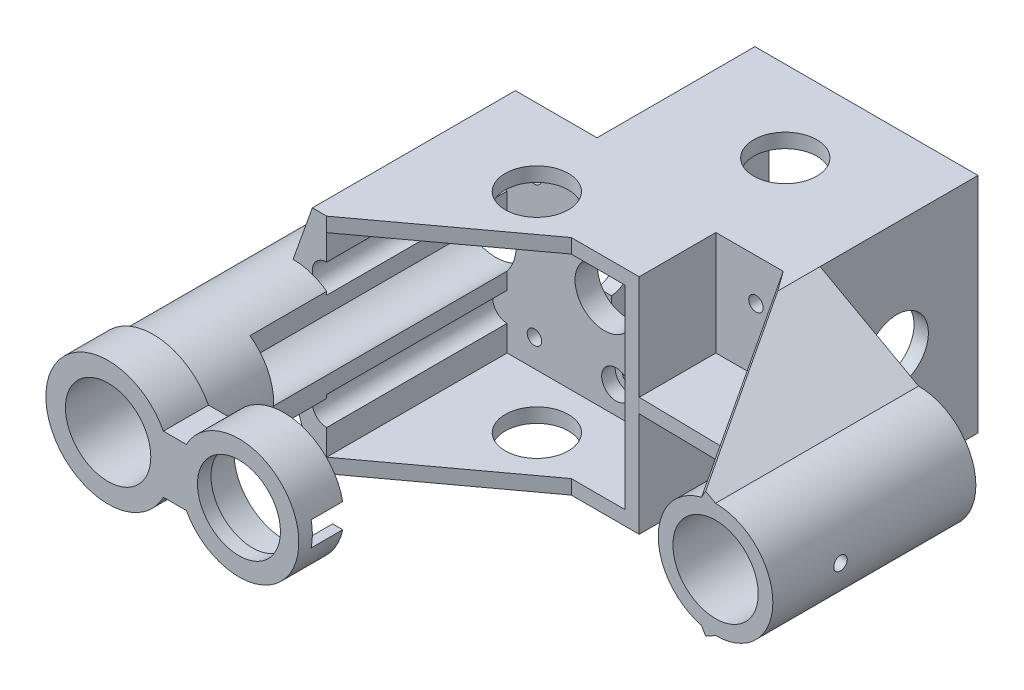
from build123d import *

# Parameters (mm, degrees)
SKETCH5_R       = 9.46
SKETCH5_R_2     = 1.6
EXTRUDE1_DEPTH  = 5
SKETCH6_R       = 9.46
EXTRUDE2_DEPTH  = 40
SKETCH7_W       = 49.45
SKETCH7_H       = 49.45
SKETCH7_W_2     = 43.1
SKETCH7_H_2     = 43.1
EXTRUDE3_DEPTH  = 35
EXTRUDE5_REACH  = 20.597
EXTRUDE6_REACH  = 20.597
SKETCH16_R      = 7
EXTRUDE9_DEPTH  = 49.45
EXTRUDE10_DEPTH = 17
SKETCH18_R      = 12.7
SKETCH18_R_2    = 9.46
EXTRUDE11_DEPTH = 14
SKETCH19_R      = 11.1
SKETCH19_R_2    = 9.46
EXTRUDE12_DEPTH = 7
SKETCH20_R      = 9.46
SKETCH20_R_2    = 9.2
EXTRUDE13_DEPTH = 3
EXTRUDE14_DEPTH = 15
SKETCH22_R      = 3.2
EXTRUDE15_DEPTH = 3
SKETCH23_R      = 3.2
EXTRUDE16_DEPTH = 3
SKETCH24_R      = 7
EXTRUDE17_DEPTH = 49.45
SKETCH25_R      = 6.5
EXTRUDE18_DEPTH = 5
EXTRUDE19_START = -25.300694
SKETCH26_R      = 1.5
EXTRUDE19_DEPTH = 119.050001


with BuildPart() as part:
    # Sketch5 → Extrude1 (new body)
    with BuildSketch(Plane.XY):
        with BuildLine():
            Line((-21.825, -24.725), (0, -12.7))
            ThreePointArc((0, -12.7), (12.7, 0), (0, 12.7))
            Line((0, 12.7), (-21.825, 24.725))
            Line((-21.825, 24.725), (-89.375, 24.725))
            Line((-89.375, 24.725), (-93.65, 12.7))
            ThreePointArc((-93.65, 12.7), (-106.35, 0), (-93.65, -12.7))
            Line((-93.65, -12.7), (-89.375, -24.725))
            Line((-89.375, -24.725), (-21.825, -24.725))
        make_face()
        Circle(SKETCH5_R, mode=Mode.SUBTRACT)
        with Locations((-93.65, 0)):
            Circle(SKETCH5_R, mode=Mode.SUBTRACT)
        with Locations((-31.05, 15.5)):
            Circle(SKETCH5_R_2, mode=Mode.SUBTRACT)
        with Locations((-31.05, -15.5)):
            Circle(SKETCH5_R_2, mode=Mode.SUBTRACT)
        with Locations((-49.15, -15.5)):
            Circle(SKETCH5_R_2, mode=Mode.SUBTRACT)
        with Locations((-49.15, 15.5)):
            Circle(SKETCH5_R_2, mode=Mode.SUBTRACT)
        with Locations((-62.05, 15.5)):
            Circle(SKETCH5_R_2, mode=Mode.SUBTRACT)
        with Locations((-80.15, 15.5)):
            Circle(SKETCH5_R_2, mode=Mode.SUBTRACT)
        with Locations((-80.15, -15.5)):
            Circle(SKETCH5_R_2, mode=Mode.SUBTRACT)
        with Locations((-62.05, -15.5)):
            Circle(SKETCH5_R_2, mode=Mode.SUBTRACT)
    extrude(amount=EXTRUDE1_DEPTH)

    # Sketch6 → Extrude2 (add)
    with BuildSketch(Plane.XY.offset(5)):
        with BuildLine():
            Line((-39.925, 24.725), (-89.375, 24.725))
            Line((-89.375, 24.725), (-93.65, 12.7))
            ThreePointArc((-93.65, 12.7), (-106.35, 0), (-93.65, -12.7))
            Line((-93.65, -12.7), (-89.375, -24.725))
            Line((-89.375, -24.725), (-39.925, -24.725))
            Line((-39.925, -24.725), (-39.925, -1.585093616))
            Line((-39.925, -1.585093616), (-12.600693561, -1.585093616))
            ThreePointArc((-12.600693561, -1.585093616), (-9.51301391, -8.413831847), (-3.112651943, -12.312651943))
            Line((-3.112651943, -12.312651943), (-25, -24.725))
            Line((-25, -24.725), (-21.825, -24.725))
            Line((-21.825, -24.725), (0, -12.7))
            ThreePointArc((0, -12.7), (12.7, 0), (0, 12.7))
            Line((0, 12.7), (-21.825, 24.725))
            Line((-21.825, 24.725), (-25, 24.725))
            Line((-25, 24.725), (-3.112651943, 12.312651943))
            ThreePointArc((-3.112651943, 12.312651943), (-9.513885465, 8.41284633), (-12.601021697, 1.58248292))
            Line((-12.601021697, 1.58248292), (-39.925, 1.58248292))
            Line((-39.925, 1.58248292), (-39.925, 24.725))
        make_face()
        Circle(SKETCH6_R, mode=Mode.SUBTRACT)
        with BuildLine():
            Line((-86.2, -21.55), (-43.1, -21.55))
            Line((-43.1, -21.55), (-43.1, 21.55))
            Line((-43.1, 21.55), (-86.2, 21.55))
            Line((-86.2, 21.55), (-86.2, 15.891608363))
            ThreePointArc((-86.2, 15.891608363), (-89.375, 12.716608363), (-86.2, 9.541608363))
            Line((-86.2, 9.541608363), (-86.2, 5.830017153))
            ThreePointArc((-86.2, 5.830017153), (-103.11, 0), (-86.2, -5.830017153))
            Line((-86.2, -5.830017153), (-86.2, -9.508391637))
            ThreePointArc((-86.2, -9.508391637), (-89.375, -12.683391637), (-86.2, -15.858391637))
            Line((-86.2, -15.858391637), (-86.2, -21.55))
        make_face(mode=Mode.SUBTRACT)
    extrude(amount=EXTRUDE2_DEPTH)

    # Sketch7 → Extrude3 (add)
    with BuildSketch(Plane(origin=(0, 0, 0), x_dir=(-1, 0, 0), z_dir=(0, 0, -1))):
        with Locations((46.55, 0)):
            Rectangle(SKETCH7_W, SKETCH7_H)
        with Locations((46.55, 0)):
            Rectangle(SKETCH7_W_2, SKETCH7_H_2, mode=Mode.SUBTRACT)
    extrude(amount=EXTRUDE3_DEPTH)

    # Extrude5: up to this face of the body (flat: up to its plane)
    extrude5_end = Plane(part.part.faces().sort_by_distance((-10.9125, 18.7125, 22.5))[0])
    # Sketch12 → Extrude5 (cut, up to the picked face)
    with BuildSketch(Plane(origin=(4.5259255, 7.980803168, 0), x_dir=(0, 0, 1), z_dir=(-0.493298857, -0.869859895, 0)), mode=Mode.PRIVATE) as extrude5_sk1:
        Polygon((45, 8.781388226), (5, 33.943311626), (45, 33.943311626), align=None)
    extrude5_tool1 = split(extrude(extrude5_sk1.sketch, amount=-EXTRUDE5_REACH, mode=Mode.PRIVATE), bisect_by=extrude5_end, keep=Keep.BOTH, mode=Mode.PRIVATE)
    add(extrude5_tool1.solids().sort_by_distance((-17.704217, 20.587551, 31.666667))[0], mode=Mode.SUBTRACT)

    # Extrude6: up to this face of the body (flat: up to its plane)
    extrude6_end = Plane(part.part.faces().sort_by_distance((-10.9125, -18.7125, 22.5))[0])
    # Sketch13 → Extrude6 (cut, up to the picked face)
    with BuildSketch(Plane(origin=(4.5259255, -7.980803168, 0), x_dir=(0, 0, 1), z_dir=(-0.493298857, 0.869859895, 0)), mode=Mode.PRIVATE) as extrude6_sk1:
        Polygon((45, -8.781388226), (5, -33.943311626), (45, -33.943311626), align=None)
    extrude6_tool1 = split(extrude(extrude6_sk1.sketch, amount=-EXTRUDE6_REACH, mode=Mode.PRIVATE), bisect_by=extrude6_end, keep=Keep.BOTH, mode=Mode.PRIVATE)
    add(extrude6_tool1.solids().sort_by_distance((-17.704217, -20.587551, 31.666667))[0], mode=Mode.SUBTRACT)

    # Sketch16 → Extrude9 (cut)
    with BuildSketch(Plane.XZ.offset(24.725)):
        with Locations((-46.55, -17)):
            Circle(SKETCH16_R)
        with Locations((-67.618096531, 17)):
            Circle(SKETCH16_R)
        Polygon((-39.925, 22), (-16.781973348, 22.403360483), (-12.600693561, 29.053940018), (-12.600693561, 45), (-86.2, 45), (-54.981583076, 22), align=None)
    extrude(amount=-EXTRUDE9_DEPTH, mode=Mode.SUBTRACT)

    # Sketch17 → Extrude10 (add)
    with BuildSketch(Plane.XY.offset(45)):
        with BuildLine():
            Line((-86.2, 10.285305051), (-86.2, 5.830017153))
            ThreePointArc((-86.2, 5.830017153), (-103.11, 0), (-86.2, -5.830017153))
            Line((-86.2, -5.830017153), (-86.2, -10.285305051))
            ThreePointArc((-86.2, -10.285305051), (-89.146529591, -11.874710703), (-92.40601106, -12.638927625))
            ThreePointArc((-92.40601106, -12.638927625), (-106.334722718, -0.62274359), (-93.65, 12.7))
            ThreePointArc((-93.65, 12.7), (-89.734222565, 12.081253539), (-86.2, 10.285305051))
        make_face()
    extrude(amount=EXTRUDE10_DEPTH)

    # Sketch18 → Extrude11 (add)
    with BuildSketch(Plane.XY.offset(62)):
        with Locations((-93.65, 0)):
            Circle(SKETCH18_R)
        with Locations((-93.65, 0)):
            Circle(SKETCH18_R_2, mode=Mode.SUBTRACT)
    extrude(amount=EXTRUDE11_DEPTH)

    # Sketch19 → Extrude12 (add)
    with BuildSketch(Plane.XY.offset(76)):
        with BuildLine():
            Line((-81.398348387, -6.344577353), (-76.315821236, -6.344577353))
            ThreePointArc((-76.315821236, -6.344577353), (-51.370502761, 0), (-76.315821236, 6.344577353))
            Line((-76.315821236, 6.344577353), (-81.398348387, 6.344577353))
            ThreePointArc((-81.398348387, 6.344577353), (-107.446978982, 0), (-81.398348387, -6.344577353))
        make_face()
        with Locations((-64.65, 0)):
            Circle(SKETCH19_R, mode=Mode.SUBTRACT)
        with Locations((-93.65, 0)):
            Circle(SKETCH19_R_2, mode=Mode.SUBTRACT)
    extrude(amount=EXTRUDE12_DEPTH)

    # Sketch20 → Extrude13 (add)
    with BuildSketch(Plane.XY.offset(83)):
        with BuildLine():
            Line((-81.398348387, -6.344577353), (-76.315821236, -6.344577353))
            ThreePointArc((-76.315821236, -6.344577353), (-51.370502761, 0), (-76.315821236, 6.344577353))
            Line((-76.315821236, 6.344577353), (-81.398348387, 6.344577353))
            ThreePointArc((-81.398348387, 6.344577353), (-107.446978982, 0), (-81.398348387, -6.344577353))
        make_face()
        with Locations((-93.65, 0)):
            Circle(SKETCH20_R, mode=Mode.SUBTRACT)
        with Locations((-64.65, 0)):
            Circle(SKETCH20_R_2, mode=Mode.SUBTRACT)
    extrude(amount=EXTRUDE13_DEPTH)

    # Sketch21 → Extrude14 (cut)
    with BuildSketch(Plane.ZY.offset(43.1)):
        Polygon((76, 0), (76, -2.7), (83, -2.7), (83, 2.7), (76, 2.7), align=None)
    extrude(amount=EXTRUDE14_DEPTH, mode=Mode.SUBTRACT)

    # Sketch22 → Extrude15 (cut)
    with BuildSketch(Plane.XY.offset(5)):
        with Locations((-62.05, 15.5)):
            Circle(SKETCH22_R)
        with Locations((-62.05, -15.5)):
            Circle(SKETCH22_R)
    extrude(amount=-EXTRUDE15_DEPTH, mode=Mode.SUBTRACT)

    # Sketch23 → Extrude16 (cut)
    with BuildSketch(Plane(origin=(0, 0, 0), x_dir=(-1, 0, 0), z_dir=(0, 0, -1))):
        with Locations((49.15, 15.5)):
            Circle(SKETCH23_R)
        with Locations((49.15, -15.5)):
            Circle(SKETCH23_R)
    extrude(amount=-EXTRUDE16_DEPTH, mode=Mode.SUBTRACT)

    # Sketch24 → Extrude17 (cut)
    with BuildSketch(Plane.ZY.offset(71.275)):
        with Locations((-17, 0)):
            Circle(SKETCH24_R)
        with BuildLine():
            Line((0, 0), (0, 4))
            ThreePointArc((0, 4), (-4, 0), (0, -4))
            Line((0, -4), (0, 0))
        make_face()
    extrude(amount=-EXTRUDE17_DEPTH, mode=Mode.SUBTRACT)

    # Sketch25 → Extrude18 (cut)
    with BuildSketch(Plane(origin=(0, 0, 0), x_dir=(-1, 0, 0), z_dir=(0, 0, -1))):
        with Locations((46.55, 0)):
            Circle(SKETCH25_R)
        with Locations((64.65, 0)):
            Circle(SKETCH25_R)
    extrude(amount=-EXTRUDE18_DEPTH, mode=Mode.SUBTRACT)

    # Sketch26 → Extrude19 (cut)
    with BuildSketch(Plane.ZY.offset(12.600693561).offset(EXTRUDE19_START)):
        with Locations((30, 0)):
            Circle(SKETCH26_R)
    extrude(amount=EXTRUDE19_DEPTH, mode=Mode.SUBTRACT)


solid = part.part
